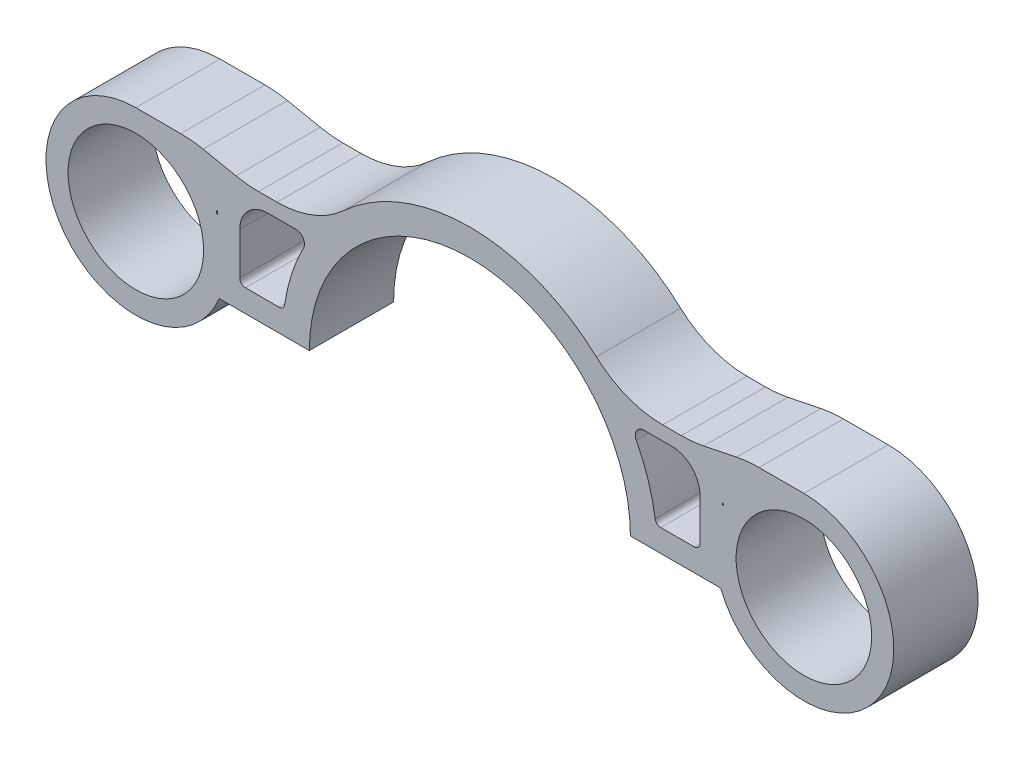
from build123d import *

# Parameters (mm, degrees)
BOSS_EXTRUDE1_DEPTH = 30
SKETCH2_W           = 20
SKETCH2_H           = 8
BOSS_EXTRUDE2_DEPTH = 30
BOSS_EXTRUDE3_DEPTH = 30
FILLET2_R           = 35
FILLET3_R           = 3
SKETCH5_R           = 2.778125
CUT_EXTRUDE2_DEPTH  = 9
SKETCH6_R           = 24.13
BOSS_EXTRUDE4_DEPTH = 30
FILLET4_R           = 40
FILLET5_R           = 10
FILLET6_R           = 2


with BuildPart() as part:
    # Sketch1 → Boss-Extrude1 (new body)
    with BuildSketch(Plane.XY):
        with BuildLine():
            ThreePointArc((66.675, 0), (0, 66.675), (-66.675, 0))
            Line((-66.675, 0), (-57.15, 0))
            ThreePointArc((-57.15, 0), (0, 57.15), (57.15, 0))
            Line((57.15, 0), (66.675, 0))
        make_face()
    extrude(amount=BOSS_EXTRUDE1_DEPTH)

    # Sketch2 → Boss-Extrude2 (add)
    with BuildSketch(Plane.XY.offset(30)):
        with Locations((-71.9125, 4)):
            Rectangle(SKETCH2_W, SKETCH2_H)
        with Locations((71.9125, 4)):
            Rectangle(SKETCH2_W, SKETCH2_H)
    extrude(amount=-BOSS_EXTRUDE2_DEPTH)

    # Sketch4 → Boss-Extrude3 (add)
    with BuildSketch(Plane.XY.offset(30)):
        with BuildLine():
            Line((-89.9125, 40), (-89.9125, 35))
            Line((-89.9125, 35), (-81.9125, 35))
            Line((-81.9125, 35), (-56.749939427, 35))
            ThreePointArc((-56.749939427, 35), (-55.103585117, 37.538653841), (-53.343749634, 40))
            Line((-53.343749634, 40), (-89.9125, 40))
        make_face()
        Polygon((-89.9125, 0), (-81.9125, 0), (-81.9125, 8), (-81.9125, 35), (-89.9125, 35), align=None)
        with BuildLine():
            Line((89.9125, 40), (53.343749634, 40))
            ThreePointArc((53.343749634, 40), (55.103585117, 37.538653841), (56.749939427, 35))
            Line((56.749939427, 35), (81.9125, 35))
            Line((81.9125, 35), (89.9125, 35))
            Line((89.9125, 35), (89.9125, 40))
        make_face()
        Polygon((89.9125, 0), (89.9125, 35), (81.9125, 35), (81.9125, 8), (81.9125, 0), align=None)
    extrude(amount=-BOSS_EXTRUDE3_DEPTH)

    # Fillet2
    fillet2_edges = [part.edges().sort_by_distance(p)[0] for p in [
        (-53.343749634, 40, 15),
        (53.343749634, 40, 15),
    ]]
    fillet(fillet2_edges, radius=FILLET2_R)

    # Fillet3
    fillet3_edges = [part.edges().sort_by_distance(p)[0] for p in [
        (-56.749939427, 35, 15),
        (56.749939427, 35, 15),
    ]]
    fillet(fillet3_edges, radius=FILLET3_R)

    # Sketch5 → Cut-Extrude2 (cut, through all)
    with BuildSketch(Plane(origin=(0, 8, 0), x_dir=(1, 0, 0), z_dir=(0, 1, 0))):
        with Locations((-74.052910047, -15)):
            Circle(SKETCH5_R)
        with Locations((74.052910047, -15)):
            Circle(SKETCH5_R)
    extrude(amount=-CUT_EXTRUDE2_DEPTH, mode=Mode.SUBTRACT)

    # Sketch6 → Boss-Extrude4 (add)
    with BuildSketch(Plane.XY.offset(30)):
        with BuildLine():
            Line((-98.9125, 44), (-118.9125, 44))
            ThreePointArc((-118.9125, 44), (-135.746949407, -15.213991129), (-90.279215199, 26.287582073))
            Line((-90.279215199, 26.287582073), (-79.281188547, 40))
            Line((-79.281188547, 40), (-98.9125, 44))
        make_face()
        with Locations((-118.9125, 12)):
            Circle(SKETCH6_R, mode=Mode.SUBTRACT)
        with BuildLine():
            Line((98.9125, 44), (79.281188547, 40))
            Line((79.281188547, 40), (90.279215199, 26.287582073))
            ThreePointArc((90.279215199, 26.287582073), (135.746949407, -15.213991129), (118.9125, 44))
            Line((118.9125, 44), (98.9125, 44))
        make_face()
        with Locations((118.9125, 12)):
            Circle(SKETCH6_R, mode=Mode.SUBTRACT)
    extrude(amount=-BOSS_EXTRUDE4_DEPTH)

    # Fillet4
    fillet4_edges = [part.edges().sort_by_distance(p)[0] for p in [
        (-98.9125, 44, 15),
        (-79.281188547, 40, 15),
        (79.281188547, 40, 15),
        (98.9125, 44, 15),
    ]]
    fillet(fillet4_edges, radius=FILLET4_R)

    # Fillet5
    fillet5_edges = [part.edges().sort_by_distance(p)[0] for p in [
        (-81.9125, 35, 15),
        (81.9125, 35, 15),
    ]]
    fillet(fillet5_edges, radius=FILLET5_R)

    # Fillet6
    fillet6_edges = [part.edges().sort_by_distance(p)[0] for p in [
        (-81.9125, 8, 15),
        (-66.193320093, 8, 15),
        (66.193320093, 8, 15),
        (81.9125, 8, 15),
    ]]
    fillet(fillet6_edges, radius=FILLET6_R)


solid = part.part
